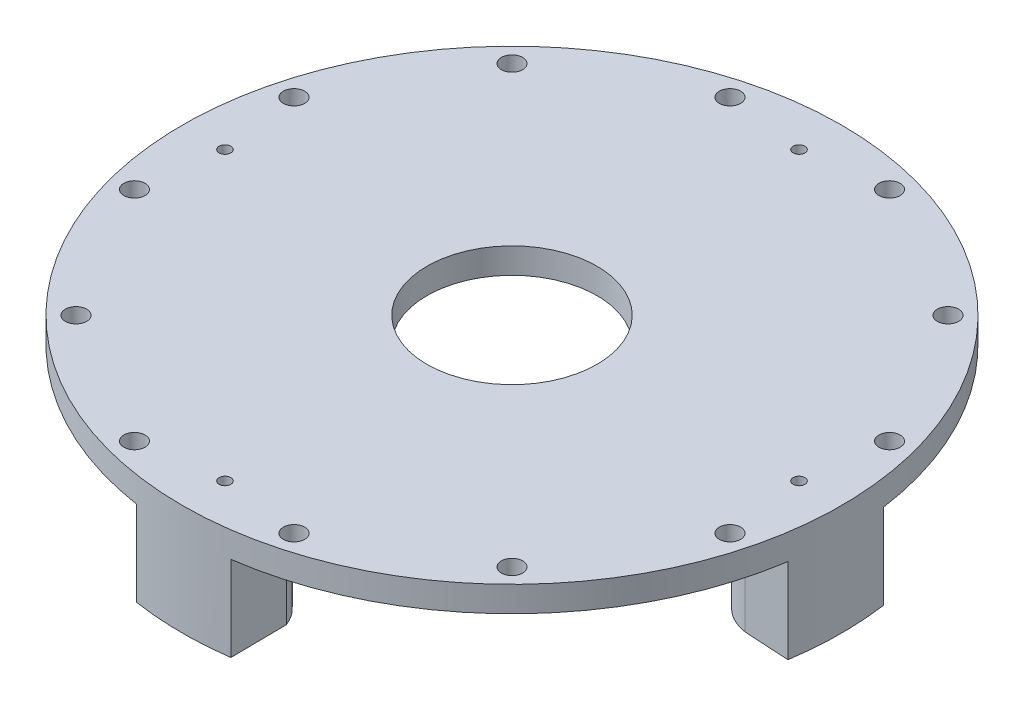
from build123d import *

# Parameters (mm, degrees)
SKETCH1_R           = 98.425
SKETCH1_R_2         = 25.4
BOSS_EXTRUDE1_DEPTH = 7.62
BOSS_EXTRUDE2_DEPTH = 25.4
SKETCH5_R           = 5.2578
CUT_EXTRUDE3_DEPTH  = 19.05
SKETCH6_R           = 3.175
CUT_EXTRUDE4_DEPTH  = 12.7
CIRPATTERN1_COUNT   = 12
CIRPATTERN2_COUNT   = 4
SKETCH8_R           = 1.7526
CUT_EXTRUDE6_DEPTH  = 34.02
CIRPATTERN3_COUNT   = 4


with BuildPart() as part:
    # Sketch1 → Boss-Extrude1 (new body)
    with BuildSketch(Plane(origin=(0, 0, 0), x_dir=(1, 0, 0), z_dir=(0, 1, 0))):
        Circle(SKETCH1_R)
        Circle(SKETCH1_R_2, mode=Mode.SUBTRACT)
    extrude(amount=BOSS_EXTRUDE1_DEPTH)

    # Sketch2 → Boss-Extrude2 (add)
    with BuildSketch(Plane.XZ):
        with BuildLine():
            Line((-14.092921054, 83.751577801), (-14.875155352, 97.29445194))
            ThreePointArc((-14.875155352, 97.29445194), (-0.679076319, 98.422657353), (13.531218764, 97.490444372))
            Line((13.531218764, 97.490444372), (13.333659481, 80.753245397))
            ThreePointArc((13.333659481, 80.753245397), (-1.546485964, 71.578862712), (-14.092921054, 83.751577801))
        make_face()
        with BuildLine():
            Line((83.751577801, 14.092921054), (97.29445194, 14.875155352))
            ThreePointArc((97.29445194, 14.875155352), (98.422657353, 0.679076319), (97.490444372, -13.531218764))
            Line((97.490444372, -13.531218764), (80.753245397, -13.333659481))
            ThreePointArc((80.753245397, -13.333659481), (71.578862712, 1.546485964), (83.751577801, 14.092921054))
        make_face()
        with BuildLine():
            Line((14.092921054, -83.751577801), (14.875155352, -97.29445194))
            ThreePointArc((14.875155352, -97.29445194), (0.679076319, -98.422657353), (-13.531218764, -97.490444372))
            Line((-13.531218764, -97.490444372), (-13.333659481, -80.753245397))
            ThreePointArc((-13.333659481, -80.753245397), (1.546485964, -71.578862712), (14.092921054, -83.751577801))
        make_face()
        with BuildLine():
            Line((-83.751577801, -14.092921054), (-97.29445194, -14.875155352))
            ThreePointArc((-97.29445194, -14.875155352), (-98.422657353, -0.679076319), (-97.490444372, 13.531218764))
            Line((-97.490444372, 13.531218764), (-80.753245397, 13.333659481))
            ThreePointArc((-80.753245397, 13.333659481), (-71.578862712, -1.546485964), (-83.751577801, -14.092921054))
        make_face()
    extrude(amount=BOSS_EXTRUDE2_DEPTH)

    # Sketch5 → Cut-Extrude3 (cut)
    with BuildSketch(Plane.XZ.offset(25.4)):
        with Locations((0, 85.725)):
            Circle(SKETCH5_R)
    cut_extrude3 = extrude(amount=-CUT_EXTRUDE3_DEPTH, mode=Mode.SUBTRACT)

    # Sketch6 → Cut-Extrude4 (cut)
    with BuildSketch(Plane(origin=(0, 7.62, 0), x_dir=(1, 0, 0), z_dir=(0, 1, 0))):
        with Locations((-23.830763578, 88.937620456)):
            Circle(SKETCH6_R)
    cut_extrude4 = extrude(amount=-CUT_EXTRUDE4_DEPTH, mode=Mode.SUBTRACT)

    # CirPattern1: Cut-Extrude4 ×12 about axis
    cirpattern1_axis = Axis((0, 0, 0), (0, 1, 0))
    for i in range(1, CIRPATTERN1_COUNT):
        add(cut_extrude4.rotate(cirpattern1_axis, i * 360 / CIRPATTERN1_COUNT), mode=Mode.SUBTRACT)

    # CirPattern2: Cut-Extrude3 ×4 about axis
    cirpattern2_axis = Axis((0, 0, 0), (0, 1, 0))
    for i in range(1, CIRPATTERN2_COUNT):
        add(cut_extrude3.rotate(cirpattern2_axis, i * 360 / CIRPATTERN2_COUNT), mode=Mode.SUBTRACT)

    # Sketch8 → Cut-Extrude6 (cut, through all)
    with BuildSketch(Plane(origin=(0, 7.62, 0), x_dir=(1, 0, 0), z_dir=(0, 1, 0))):
        with Locations((0, 85.725)):
            Circle(SKETCH8_R)
    cut_extrude6 = extrude(amount=-CUT_EXTRUDE6_DEPTH, mode=Mode.SUBTRACT)

    # CirPattern3: Cut-Extrude6 ×4 about axis
    cirpattern3_axis = Axis((0, 0, 0), (0, 1, 0))
    for i in range(1, CIRPATTERN3_COUNT):
        add(cut_extrude6.rotate(cirpattern3_axis, i * 360 / CIRPATTERN3_COUNT), mode=Mode.SUBTRACT)


solid = part.part
